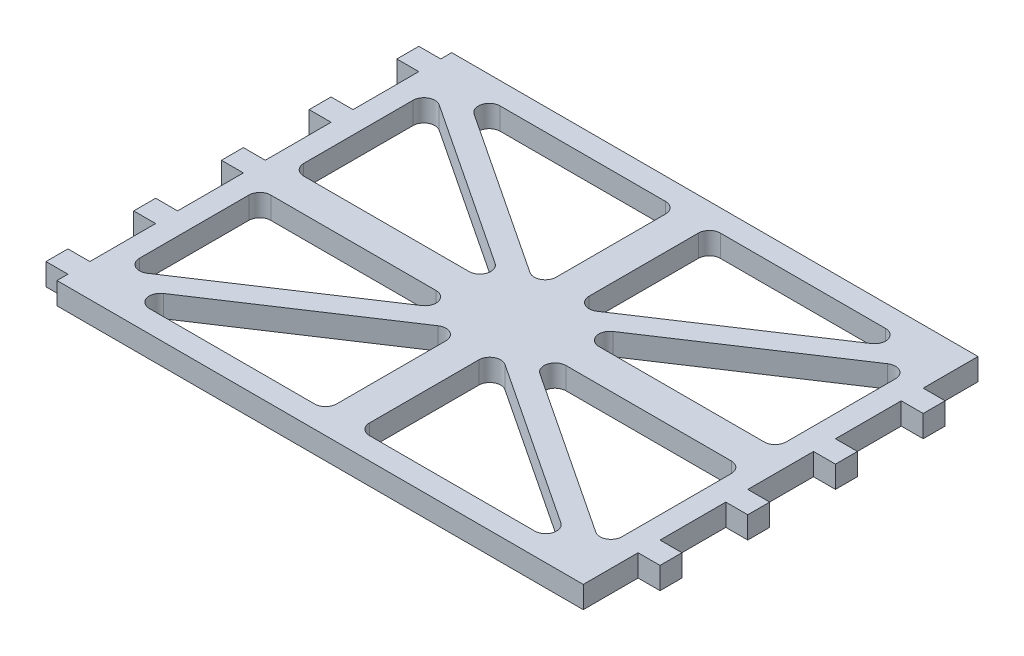
from build123d import *

# Parameters (mm, degrees)
BOSS_EXTRUDE1_DEPTH = 4
CUT_EXTRUDE1_DEPTH  = 10


with BuildPart() as part:
    # Sketch1 → Boss-Extrude1 (new body)
    with BuildSketch(Plane(origin=(0, 0, 0), x_dir=(1, 0, 0), z_dir=(0, 1, 0))):
        Polygon((-17.714285714, 14), (-17.714285714, 12), (-21.714285714, 12), (-21.714285714, 8), (-17.714285714, 8), (-17.714285714, -4), (-21.714285714, -4), (-21.714285714, -8), (-17.714285714, -8), (-17.714285714, -20), (-21.714285714, -20), (-21.714285714, -24), (-17.714285714, -24), (-17.714285714, -36), (-21.714285714, -36), (-21.714285714, -40), (-17.714285714, -40), (-17.714285714, -52), (-21.714285714, -52), (-21.714285714, -56), (-17.714285714, -56), (-17.714285714, -58), (78.285714286, -58), (78.285714286, -48), (82.285714286, -48), (82.285714286, -44), (78.285714286, -44), (78.285714286, -32), (82.285714286, -32), (82.285714286, -28), (78.285714286, -28), (78.285714286, -16), (82.285714286, -16), (82.285714286, -12), (78.285714286, -12), (78.285714286, 0), (82.285714286, 0), (82.285714286, 4), (78.285714286, 4), (78.285714286, 14), align=None)
    extrude(amount=-BOSS_EXTRUDE1_DEPTH)

    # Sketch2 → Cut-Extrude1 (cut)
    with BuildSketch(Plane(origin=(0, 0, 0), x_dir=(1, 0, 0), z_dir=(0, 1, 0))):
        with BuildLine():
            Line((-4.859302854, 10), (25.285714286, 10))
            ThreePointArc((25.285714286, 10), (26.699927848, 9.414213562), (27.285714286, 8))
            Line((27.285714286, 8), (27.285714286, -11.94278394))
            ThreePointArc((27.285714286, -11.94278394), (26.23255212, -13.704458744), (24.182216171, -13.610804297))
            Line((24.182216171, -13.610804297), (-5.962800969, 6.331979643))
            ThreePointArc((-5.962800969, 6.331979643), (-6.774510508, 8.576176746), (-4.859302854, 10))
        make_face()
        with BuildLine():
            Line((33.285714286, 8), (33.285714286, -11.94278394))
            ThreePointArc((33.285714286, -11.94278394), (34.338876451, -13.704458744), (36.3892124, -13.610804297))
            Line((36.3892124, -13.610804297), (66.53422954, 6.331979643))
            ThreePointArc((66.53422954, 6.331979643), (67.345939079, 8.576176746), (65.430731426, 10))
            Line((65.430731426, 10), (35.285714286, 10))
            ThreePointArc((35.285714286, 10), (33.871500723, 9.414213562), (33.285714286, 8))
        make_face()
        with BuildLine():
            ThreePointArc((74.285714286, -17), (73.699927848, -18.414213562), (72.285714286, -19))
            Line((72.285714286, -19), (42.140697146, -19))
            ThreePointArc((42.140697146, -19), (40.225489492, -17.576176746), (41.037199031, -15.331979643))
            Line((41.037199031, -15.331979643), (71.182216171, 4.610804297))
            ThreePointArc((71.182216171, 4.610804297), (73.23255212, 4.704458744), (74.285714286, 2.94278394))
            Line((74.285714286, 2.94278394), (74.285714286, -17))
        make_face()
        with BuildLine():
            ThreePointArc((74.285714286, -46.94278394), (73.23255212, -48.704458744), (71.182216171, -48.610804297))
            Line((71.182216171, -48.610804297), (41.037199031, -28.668020357))
            ThreePointArc((41.037199031, -28.668020357), (40.225489492, -26.423823254), (42.140697146, -25))
            Line((42.140697146, -25), (72.285714286, -25))
            ThreePointArc((72.285714286, -25), (73.699927848, -25.585786438), (74.285714286, -27))
            Line((74.285714286, -27), (74.285714286, -46.94278394))
        make_face()
        with BuildLine():
            Line((65.430731426, -54), (35.285714286, -54))
            ThreePointArc((35.285714286, -54), (33.871500723, -53.414213562), (33.285714286, -52))
            Line((33.285714286, -52), (33.285714286, -32.05721606))
            ThreePointArc((33.285714286, -32.05721606), (34.338876451, -30.295541256), (36.3892124, -30.389195703))
            Line((36.3892124, -30.389195703), (66.53422954, -50.331979643))
            ThreePointArc((66.53422954, -50.331979643), (67.345939079, -52.576176746), (65.430731426, -54))
        make_face()
        with BuildLine():
            Line((27.285714286, -52), (27.285714286, -32.05721606))
            ThreePointArc((27.285714286, -32.05721606), (26.23255212, -30.295541256), (24.182216171, -30.389195703))
            Line((24.182216171, -30.389195703), (-5.962800969, -50.331979643))
            ThreePointArc((-5.962800969, -50.331979643), (-6.774510508, -52.576176746), (-4.859302854, -54))
            Line((-4.859302854, -54), (25.285714286, -54))
            ThreePointArc((25.285714286, -54), (26.699927848, -53.414213562), (27.285714286, -52))
        make_face()
        with BuildLine():
            ThreePointArc((-13.714285714, -27), (-13.128499277, -25.585786438), (-11.714285714, -25))
            Line((-11.714285714, -25), (18.430731426, -25))
            ThreePointArc((18.430731426, -25), (20.345939079, -26.423823254), (19.53422954, -28.668020357))
            Line((19.53422954, -28.668020357), (-10.6107876, -48.610804297))
            ThreePointArc((-10.6107876, -48.610804297), (-12.661123549, -48.704458744), (-13.714285714, -46.94278394))
            Line((-13.714285714, -46.94278394), (-13.714285714, -27))
        make_face()
        with BuildLine():
            ThreePointArc((-13.714285714, 2.94278394), (-12.661123549, 4.704458744), (-10.6107876, 4.610804297))
            Line((-10.6107876, 4.610804297), (19.53422954, -15.331979643))
            ThreePointArc((19.53422954, -15.331979643), (20.345939079, -17.576176746), (18.430731426, -19))
            Line((18.430731426, -19), (-11.714285714, -19))
            ThreePointArc((-11.714285714, -19), (-13.128499277, -18.414213562), (-13.714285714, -17))
            Line((-13.714285714, -17), (-13.714285714, 2.94278394))
        make_face()
    extrude(amount=-CUT_EXTRUDE1_DEPTH, mode=Mode.SUBTRACT)


solid = part.part
